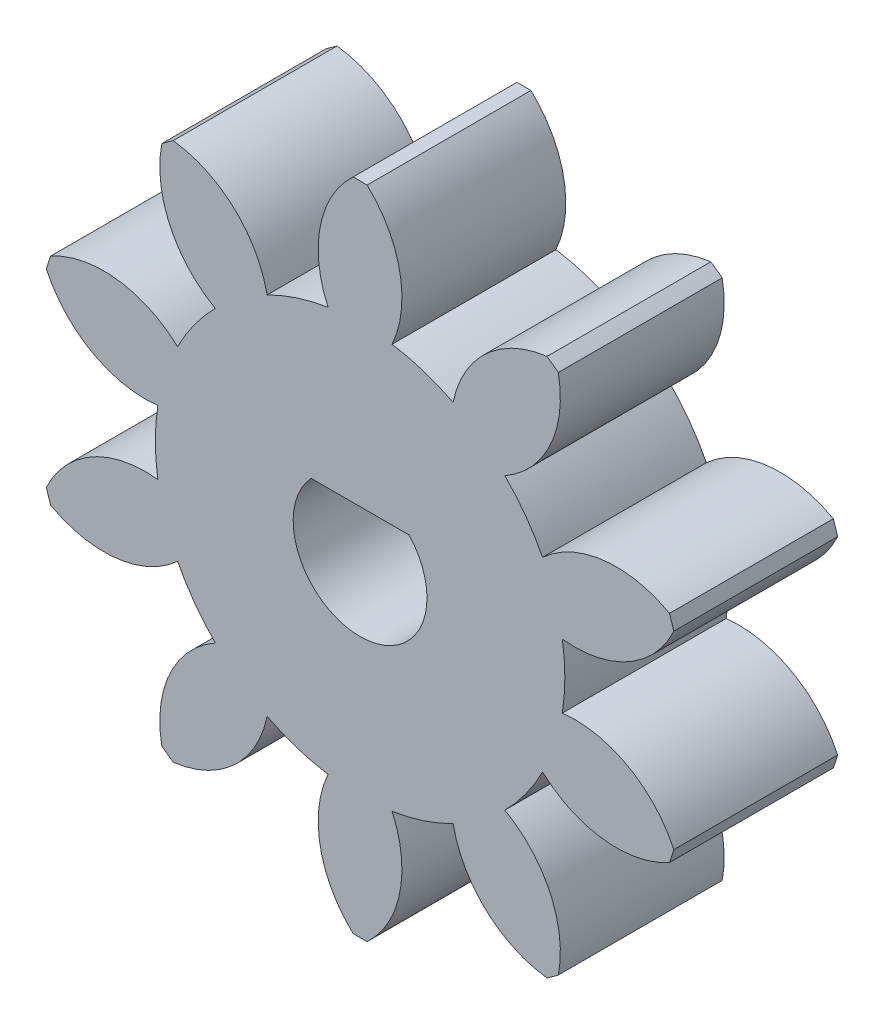
from build123d import *

# Parameters (mm, degrees)
SKETCH4_R           = 2
BOSS_EXTRUDE3_DEPTH = 6
SKETCH6_R           = 3.276903459
BOSS_EXTRUDE4_DEPTH = 6
CUT_EXTRUDE1_DEPTH  = 10


with BuildPart() as part:
    # Sketch4 → Boss-Extrude3 (new body)
    with BuildSketch(Plane.XY):
        with BuildLine():
            ThreePointArc((11.330682707, 3.9516616), (8.917819898, 4.428819506), (6.681915604, 3.403968986))
            ThreePointArc((6.681915604, 3.403968986), (6.066818441, 4.407801607), (5.302192362, 5.302995112))
            ThreePointArc((5.302192362, 5.302995112), (6.967815552, 7.112770233), (7.259627029, 9.554989032))
            ThreePointArc((7.259627029, 9.554989032), (7.053423028, 9.708203932), (6.843986457, 9.856969584))
            ThreePointArc((6.843986457, 9.856969584), (4.61147306, 8.824753264), (3.40498051, 6.681400208))
            ThreePointArc((3.40498051, 6.681400208), (2.317318441, 7.131972816), (1.172541409, 7.406763642))
            ThreePointArc((1.172541409, 7.406763642), (1.456299749, 9.849931218), (0.256880001, 11.997250213))
            ThreePointArc((0.256880001, 11.997250213), (0, 12), (-0.256880001, 11.997250213))
            ThreePointArc((-0.256880001, 11.997250213), (-1.456299749, 9.849931218), (-1.172541409, 7.406763642))
            ThreePointArc((-1.172541409, 7.406763642), (-2.317318441, 7.131972816), (-3.404980509, 6.681400207))
            ThreePointArc((-3.404980509, 6.681400207), (-4.61147306, 8.824753264), (-6.843986457, 9.856969584))
            ThreePointArc((-6.843986457, 9.856969584), (-7.053423028, 9.708203933), (-7.259627029, 9.554989032))
            ThreePointArc((-7.259627029, 9.554989032), (-6.967815552, 7.112770233), (-5.302192362, 5.302995112))
            ThreePointArc((-5.302192362, 5.302995112), (-6.066818441, 4.407801607), (-6.681915604, 3.403968986))
            ThreePointArc((-6.681915604, 3.403968986), (-8.917819898, 4.428819506), (-11.330682707, 3.9516616))
            ThreePointArc((-11.330682707, 3.9516616), (-11.412678196, 3.708203933), (-11.489443278, 3.463046803))
            ThreePointArc((-11.489443278, 3.463046803), (-9.817862641, 1.658772773), (-7.406586048, 1.173662691))
            ThreePointArc((-7.406586048, 1.173662691), (-7.499, 0), (-7.406586048, -1.173662691))
            ThreePointArc((-7.406586048, -1.173662691), (-9.817862641, -1.658772773), (-11.489443278, -3.463046803))
            ThreePointArc((-11.489443278, -3.463046803), (-11.412678196, -3.708203933), (-11.330682707, -3.9516616))
            ThreePointArc((-11.330682707, -3.9516616), (-8.917819898, -4.428819506), (-6.681915604, -3.403968986))
            ThreePointArc((-6.681915604, -3.403968986), (-6.066818441, -4.407801607), (-5.302192362, -5.302995112))
            ThreePointArc((-5.302192362, -5.302995112), (-6.967815552, -7.112770233), (-7.259627029, -9.554989032))
            ThreePointArc((-7.259627029, -9.554989032), (-7.053423028, -9.708203932), (-6.843986457, -9.856969584))
            ThreePointArc((-6.843986457, -9.856969584), (-4.61147306, -8.824753264), (-3.404980509, -6.681400207))
            ThreePointArc((-3.404980509, -6.681400207), (-2.317318441, -7.131972816), (-1.172541409, -7.406763642))
            ThreePointArc((-1.172541409, -7.406763642), (-1.456299749, -9.849931218), (-0.256880001, -11.997250213))
            ThreePointArc((-0.256880001, -11.997250213), (0, -12), (0.256880001, -11.997250213))
            ThreePointArc((0.256880001, -11.997250213), (1.456299749, -9.849931218), (1.172541409, -7.406763642))
            ThreePointArc((1.172541409, -7.406763642), (2.317318441, -7.131972816), (3.404980509, -6.681400207))
            ThreePointArc((3.404980509, -6.681400207), (4.61147306, -8.824753264), (6.843986457, -9.856969584))
            ThreePointArc((6.843986457, -9.856969584), (7.053423027, -9.708203933), (7.259627029, -9.554989032))
            ThreePointArc((7.259627029, -9.554989032), (6.967815552, -7.112770233), (5.302192362, -5.302995112))
            ThreePointArc((5.302192362, -5.302995112), (6.066818441, -4.407801607), (6.681915604, -3.403968986))
            ThreePointArc((6.681915604, -3.403968986), (8.917819898, -4.428819506), (11.330682707, -3.9516616))
            ThreePointArc((11.330682707, -3.9516616), (11.412678196, -3.708203932), (11.489443278, -3.463046803))
            ThreePointArc((11.489443278, -3.463046803), (9.817862641, -1.658772773), (7.406586048, -1.173662691))
            ThreePointArc((7.406586048, -1.173662691), (7.499, 0), (7.406586048, 1.173662691))
            ThreePointArc((7.406586048, 1.173662691), (9.817862641, 1.658772773), (11.489443278, 3.463046803))
            ThreePointArc((11.489443278, 3.463046803), (11.412678196, 3.708203932), (11.330682707, 3.9516616))
        make_face()
        Circle(SKETCH4_R, mode=Mode.SUBTRACT)
    extrude(amount=BOSS_EXTRUDE3_DEPTH)

    # Sketch6 → Boss-Extrude4 (add)
    with BuildSketch(Plane.XY.offset(6)):
        Circle(SKETCH6_R)
    extrude(amount=-BOSS_EXTRUDE4_DEPTH)

    # Sketch7 → Cut-Extrude1 (cut)
    with BuildSketch(Plane.XY.offset(6)):
        with BuildLine():
            Line((-1.792651667, 1.67), (1.792651667, 1.67))
            ThreePointArc((1.792651667, 1.67), (0, -2.45), (-1.792651667, 1.67))
        make_face()
    extrude(amount=-CUT_EXTRUDE1_DEPTH, mode=Mode.SUBTRACT)


solid = part.part
